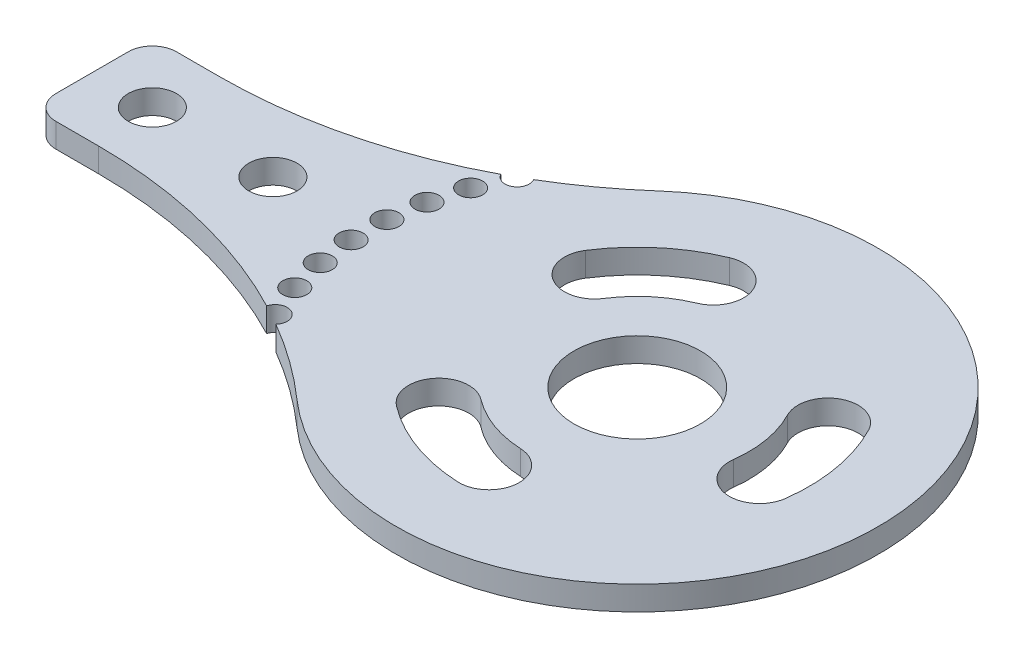
from build123d import *

# Parameters (mm, degrees)
EXTRUDE_1_DEPTH          = 2
SKETCH_2_R               = 1
CUT_EXTRUDE_1_DEPTH      = 3
PATTERN_CIRCULAR_1_COUNT = 8
PATTERN_CIRCULAR_1_ANGLE = 52.5
SKETCH_3_R               = 2
CUT_EXTRUDE_2_DEPTH      = 3
PATTERN_LINEAR_1_COUNT   = 2
PATTERN_LINEAR_1_PITCH   = 10
CUT_EXTRUDE_4_DEPTH      = 3
PATTERN_CIRCULAR_3_COUNT = 3
SKETCH_7_R               = 5.25
CUT_EXTRUDE_5_DEPTH      = 3


with BuildPart() as part:
    # Эскиз1 → Бобышка-Вытянуть1 (new body)
    with BuildSketch(Plane(origin=(0, 0, 0), x_dir=(1, 0, 0), z_dir=(0, 1, 0))):
        with BuildLine():
            Line((0, -2), (0, -8))
            ThreePointArc((0, -8), (0.585786438, -9.414213562), (2, -10))
            Line((2, -10), (5.542486889, -10))
            ThreePointArc((5.542486889, -10), (19.684622513, -12.583426132), (32, -20))
            ThreePointArc((32, -20), (65.228756555, -5), (32, 10))
            ThreePointArc((32, 10), (19.684622513, 2.583426132), (5.542486889, 0))
            Line((5.542486889, 0), (2, 0))
            ThreePointArc((2, 0), (0.585786438, -0.585786438), (0, -2))
        make_face()
    extrude(amount=EXTRUDE_1_DEPTH)

    # Эскиз2 → Вырез-Вытянуть1 (cut, through all)
    with BuildSketch(Plane(origin=(0, 2, 0), x_dir=(1, 0, 0), z_dir=(0, 1, 0))):
        with Locations((25.137189268, 5.128125392)):
            Circle(SKETCH_2_R)
    cut_extrude_1 = extrude(amount=-CUT_EXTRUDE_1_DEPTH, mode=Mode.SUBTRACT)

    # Круговой массив1: Вырез-Вытянуть1 ×8 about axis
    pattern_circular_1_axis = Axis((45.228756555, 0, 5), (0, 1, 0))
    for i in range(1, PATTERN_CIRCULAR_1_COUNT):
        add(cut_extrude_1.rotate(pattern_circular_1_axis, i * PATTERN_CIRCULAR_1_ANGLE / (PATTERN_CIRCULAR_1_COUNT - 1)), mode=Mode.SUBTRACT)

    # Эскиз3 → Вырез-Вытянуть2 (cut, through all)
    with BuildSketch(Plane(origin=(0, 2, 0), x_dir=(1, 0, 0), z_dir=(0, 1, 0))):
        with Locations((5, -5)):
            Circle(SKETCH_3_R)
    cut_extrude_2 = extrude(amount=-CUT_EXTRUDE_2_DEPTH, mode=Mode.SUBTRACT)

    # Линейный массив1: Вырез-Вытянуть2 ×2
    with Locations(*[(i * PATTERN_LINEAR_1_PITCH, 0, 0) for i in range(1, PATTERN_LINEAR_1_COUNT)]):
        add(cut_extrude_2, mode=Mode.SUBTRACT)

    # Эскиз6 → Вырез-Вытянуть4 (cut, through all)
    with BuildSketch(Plane(origin=(0, 2, 0), x_dir=(1, 0, 0), z_dir=(0, 1, 0))):
        with BuildLine():
            ThreePointArc((37.446222009, -0.000750623), (39.288664725, 2.090532233), (41.67041088, 3.538062681))
            ThreePointArc((41.67041088, 3.538062681), (43.016297342, 6.807403537), (39.746956487, 8.153289999))
            ThreePointArc((39.746956487, 8.153289999), (36.077763715, 5.923300776), (33.239393437, 2.701580475))
            ThreePointArc((33.239393437, 2.701580475), (33.991642174, -0.75299936), (37.446222009, -0.000750623))
        make_face()
    cut_extrude_4 = extrude(amount=-CUT_EXTRUDE_4_DEPTH, mode=Mode.SUBTRACT)

    # Круговой массив3: Вырез-Вытянуть4 ×3 about axis
    pattern_circular_3_axis = Axis((45.228756555, 0, 5), (0, 1, 0))
    for i in range(1, PATTERN_CIRCULAR_3_COUNT):
        add(cut_extrude_4.rotate(pattern_circular_3_axis, i * 360 / PATTERN_CIRCULAR_3_COUNT), mode=Mode.SUBTRACT)

    # Эскиз7 → Вырез-Вытянуть5 (cut, through all)
    with BuildSketch(Plane(origin=(0, 2, 0), x_dir=(1, 0, 0), z_dir=(0, 1, 0))):
        with Locations((45.228756555, -5)):
            Circle(SKETCH_7_R)
    extrude(amount=-CUT_EXTRUDE_5_DEPTH, mode=Mode.SUBTRACT)


solid = part.part
